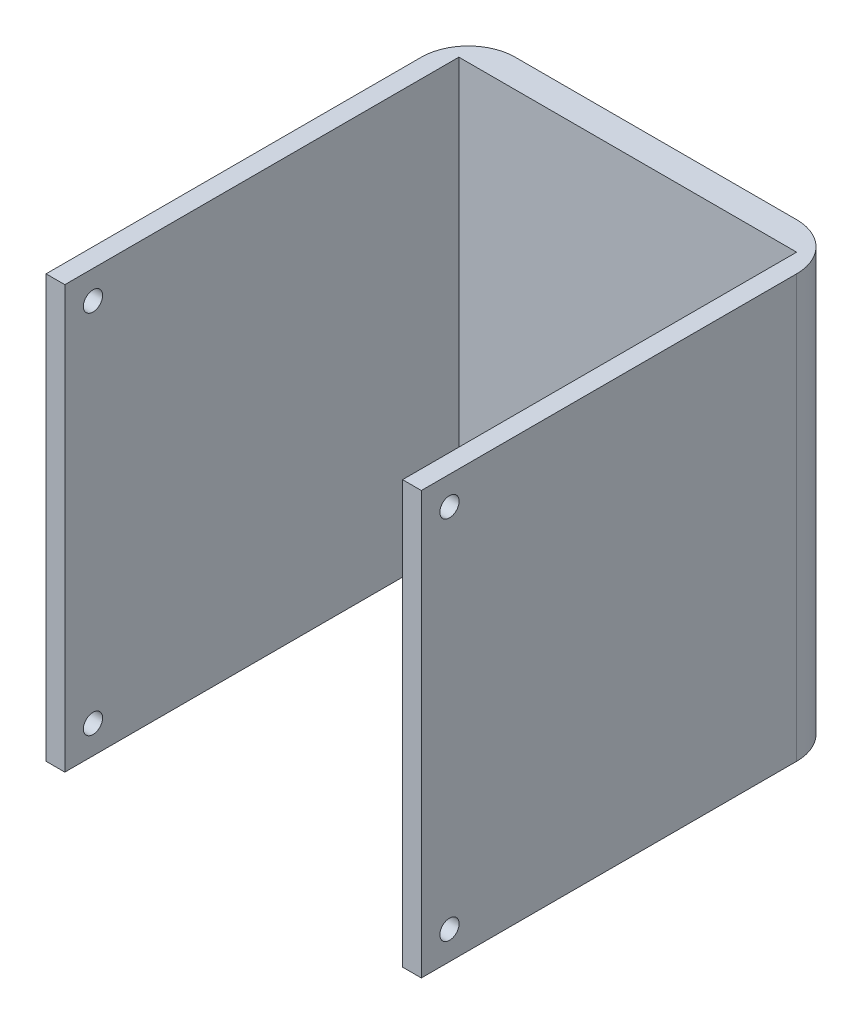
from build123d import *

# Parameters (mm, degrees)
SKETCH_1_W           = 40
SKETCH_1_H           = 45
EXTRUDE_1_DEPTH      = 40
EXTRUDE_1_DEPTH_BACK = 5
SKETCH_2_W           = 36
SKETCH_2_H           = 37
CUT_EXTRUDE_1_DEPTH  = 50
SKETCH_3_R           = 1.025
CUT_EXTRUDE_2_DEPTH  = 2
SKETCH_4_R           = 1.025
CUT_EXTRUDE_3_DEPTH  = 2
SKETCH_5_W           = 36
SKETCH_5_H           = 5
CUT_EXTRUDE_4_DEPTH  = 43
FILLET_6_R           = 5
FILLET_7_R           = 5


with BuildPart() as part:
    # 草圖1 → 填料-伸長1 (new body, two sides)
    with BuildSketch(Plane.XY) as extrude_1_sk:
        with Locations((5.454545455, -5.590909091)):
            Rectangle(SKETCH_1_W, SKETCH_1_H)
    extrude(amount=EXTRUDE_1_DEPTH)
    extrude(extrude_1_sk.sketch, amount=-EXTRUDE_1_DEPTH_BACK)

    # 草圖2 → 除料-伸長1 (cut)
    with BuildSketch(Plane(origin=(0, 16.909090909, 0), x_dir=(1, 0, 0), z_dir=(0, 1, 0))):
        with Locations((5.454545455, -21.5)):
            Rectangle(SKETCH_2_W, SKETCH_2_H)
    extrude(amount=-CUT_EXTRUDE_1_DEPTH, mode=Mode.SUBTRACT)

    # 草圖3 → 除料-伸長2 (cut)
    with BuildSketch(Plane.ZY.offset(14.545454545)):
        with Locations((37, -25.090909091)):
            Circle(SKETCH_3_R)
        with Locations((37, 13.909090909)):
            Circle(SKETCH_3_R)
    extrude(amount=-CUT_EXTRUDE_2_DEPTH, mode=Mode.SUBTRACT)

    # 草圖4 → 除料-伸長3 (cut)
    with BuildSketch(Plane(origin=(25.454545455, 0, 0), x_dir=(0, 0, -1), z_dir=(1, 0, 0))):
        with Locations((-37, 13.909090909)):
            Circle(SKETCH_4_R)
        with Locations((-37, -25.090909091)):
            Circle(SKETCH_4_R)
    extrude(amount=-CUT_EXTRUDE_3_DEPTH, mode=Mode.SUBTRACT)

    # 草圖5 → 除料-伸長4 (cut)
    with BuildSketch(Plane(origin=(0, 16.909090909, 0), x_dir=(1, 0, 0), z_dir=(0, 1, 0))):
        with Locations((5.454545455, -0.5)):
            Rectangle(SKETCH_5_W, SKETCH_5_H)
    extrude(amount=-CUT_EXTRUDE_4_DEPTH, mode=Mode.SUBTRACT)

    # 圓角6
    fillet_6_edges = [part.edges().sort_by_distance(p)[0] for p in [
        (-14.545454545, -5.590909091, -5),
    ]]
    fillet(fillet_6_edges, radius=FILLET_6_R)

    # 圓角7
    fillet_7_edges = [part.edges().sort_by_distance(p)[0] for p in [
        (25.454545455, -5.590909091, -5),
    ]]
    fillet(fillet_7_edges, radius=FILLET_7_R)


solid = part.part
